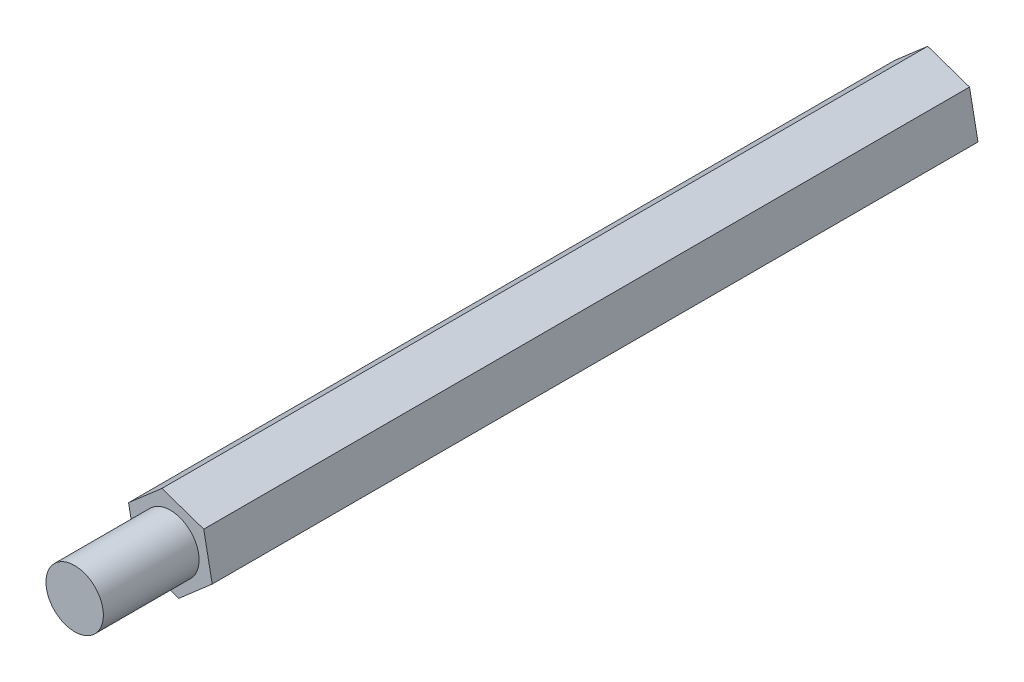
from build123d import *

# Parameters (mm, degrees)
BOSS_EXTRUDE1_DEPTH = 40
SKETCH2_R           = 1.5
BOSS_EXTRUDE2_DEPTH = 5


with BuildPart() as part:
    # Sketch1 → Boss-Extrude1 (new body)
    with BuildSketch(Plane.XY):
        Polygon((2.184049568, -0.75050704), (1.741982946, 1.516188889), (-0.442066622, 2.266695929), (-2.184049568, 0.75050704), (-1.741982946, -1.516188889), (0.442066622, -2.266695929), align=None)
    extrude(amount=BOSS_EXTRUDE1_DEPTH)

    # Sketch2 → Boss-Extrude2 (add)
    with BuildSketch(Plane.XY.offset(40)):
        Circle(SKETCH2_R)
    extrude(amount=BOSS_EXTRUDE2_DEPTH)


solid = part.part
